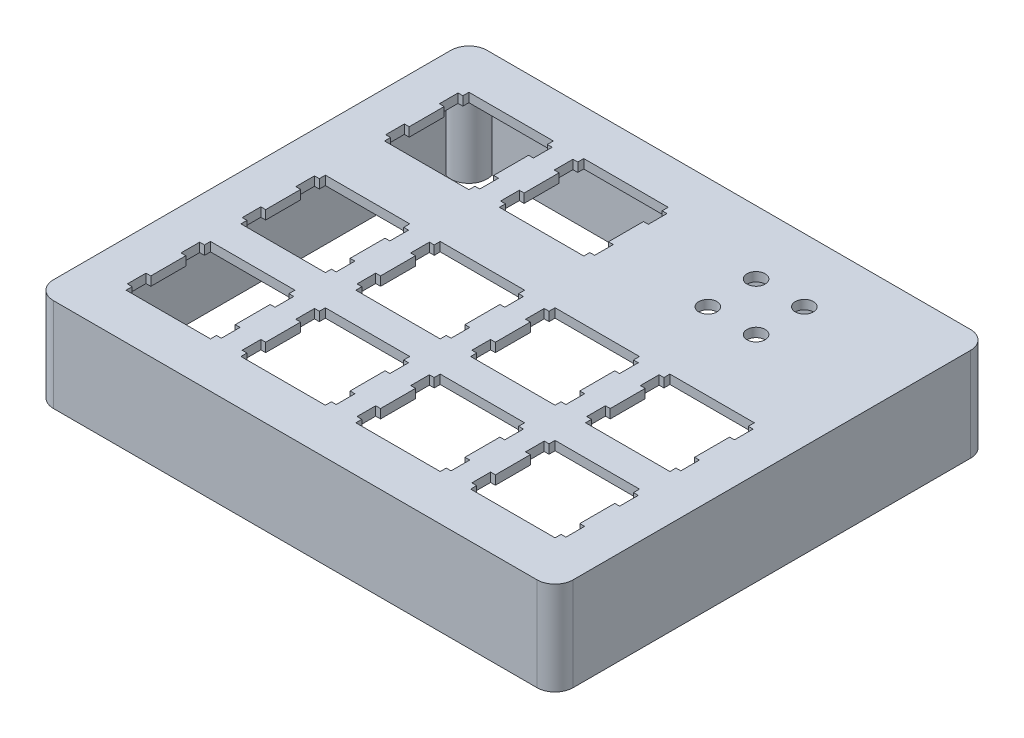
from build123d import *

# Parameters (mm, degrees)
MODEL_W                       = 86.200998775
MODEL_H                       = 71.913003996
MODEL_R                       = 1.5
BOSS_EXTRUDE1_DEPTH           = 1.5
SKETCH1_W                     = 86.200998775
SKETCH1_H                     = 71.913003996
SKETCH1_W_2                   = 82.200998775
SKETCH1_H_2                   = 67.913003996
EXTRUDE_THIN1_DEPTH           = 14
FILLET1_R                     = 3
SKETCH2_R                     = 3
BOSS_EXTRUDE2_DEPTH           = 14
TAP_DRILL_FOR_2_56_TAP1_D     = 1.778
TAP_DRILL_FOR_2_56_TAP1_DEPTH = 12.7
TAP_DRILL_FOR_2_56_TAP1_TIP   = 0.53416509
SKETCH6_W                     = 8
SKETCH6_H                     = 13
CUT_EXTRUDE1_DEPTH            = 2


with BuildPart() as part:
    # Model → Boss-Extrude1 (new body)
    with BuildSketch(Plane(origin=(0, 0, -8.60826899), x_dir=(1, 0, 0), z_dir=(0, 1, 0))):
        with Locations((43.100499388, 27.348233008)):
            Rectangle(MODEL_W, MODEL_H)
        with Locations((58.150003239, 52.780234713)):
            Circle(MODEL_R, mode=Mode.SUBTRACT)
        with Locations((66.150003239, 52.780234713)):
            Circle(MODEL_R, mode=Mode.SUBTRACT)
        with Locations((66.150003239, 44.780234713)):
            Circle(MODEL_R, mode=Mode.SUBTRACT)
        with Locations((58.150003239, 44.780234713)):
            Circle(MODEL_R, mode=Mode.SUBTRACT)
        Polygon((64.675004835, 12.91773258), (64.675004835, 11.917732552), (63.875001761, 11.917732552), (63.875001761, 8.817733992), (64.675004835, 8.817733992), (64.675004835, 3.017730781), (63.875001761, 3.017730781), (63.875001761, -0.082267779), (64.675004835, -0.082267779), (64.675004835, -1.082267806), (78.67500522, -1.082267806), (78.67500522, -0.082267779), (79.475000665, -0.082267779), (79.475000665, 3.017730781), (78.67500522, 3.017730781), (78.67500522, 8.817733992), (79.475000665, 8.817733992), (79.475000665, 11.917732552), (78.67500522, 11.917732552), (78.67500522, 12.91773258), align=None, mode=Mode.SUBTRACT)
        Polygon((45.625001258, 12.91773258), (45.625001258, 11.917732552), (44.825001999, 11.917732552), (44.825001999, 8.817733992), (45.625001258, 8.817733992), (45.625001258, 3.017730781), (44.825001999, 3.017730781), (44.825001999, -0.082267779), (45.625001258, -0.082267779), (45.625001258, -1.082267806), (59.625001644, -1.082267806), (59.625001644, -0.082267779), (60.425004717, -0.082267779), (60.425004717, 3.017730781), (59.625001644, 3.017730781), (59.625001644, 8.817733992), (60.425004717, 8.817733992), (60.425004717, 11.917732552), (59.625001644, 11.917732552), (59.625001644, 12.91773258), align=None, mode=Mode.SUBTRACT)
        Polygon((26.575001495, 12.91773258), (26.575001495, 11.917732552), (25.775000329, 11.917732552), (25.775000329, 8.817733992), (26.575001495, 8.817733992), (26.575001495, 3.017730781), (25.775000329, 3.017730781), (25.775000329, -0.082267779), (26.575001495, -0.082267779), (26.575001495, -1.082267806), (40.575001881, -1.082267806), (40.575001881, -0.082267779), (41.375001141, -0.082267779), (41.375001141, 3.017730781), (40.575001881, 3.017730781), (40.575001881, 8.817733992), (41.375001141, 8.817733992), (41.375001141, 11.917732552), (40.575001881, 11.917732552), (40.575001881, 12.91773258), align=None, mode=Mode.SUBTRACT)
        Polygon((7.524000375, 12.91773258), (7.524000375, 11.917732552), (6.724000162, 11.917732552), (6.724000162, 8.817733992), (7.524000375, 8.817733992), (7.524000375, 3.017730781), (6.724000162, 3.017730781), (6.724000162, -0.082267779), (7.524000375, -0.082267779), (7.524000375, -1.082267806), (21.525000212, -1.082267806), (21.525000212, -0.082267779), (22.325001378, -0.082267779), (22.325001378, 3.017730781), (21.525000212, 3.017730781), (21.525000212, 8.817733992), (22.325001378, 8.817733992), (22.325001378, 11.917732552), (21.525000212, 11.917732552), (21.525000212, 12.91773258), align=None, mode=Mode.SUBTRACT)
        Polygon((64.675004835, 31.967732342), (64.675004835, 30.967732314), (63.875001761, 30.967732314), (63.875001761, 27.867733755), (64.675004835, 27.867733755), (64.675004835, 22.067734358), (63.875001761, 22.067734358), (63.875001761, 18.967731983), (64.675004835, 18.967731983), (64.675004835, 17.967731956), (78.67500522, 17.967731956), (78.67500522, 18.967731983), (79.475000665, 18.967731983), (79.475000665, 22.067734358), (78.67500522, 22.067734358), (78.67500522, 27.867733755), (79.475000665, 27.867733755), (79.475000665, 30.967732314), (78.67500522, 30.967732314), (78.67500522, 31.967732342), align=None, mode=Mode.SUBTRACT)
        Polygon((45.625001258, 31.967732342), (45.625001258, 30.967732314), (44.825001999, 30.967732314), (44.825001999, 27.867733755), (45.625001258, 27.867733755), (45.625001258, 22.067734358), (44.825001999, 22.067734358), (44.825001999, 18.967731983), (45.625001258, 18.967731983), (45.625001258, 17.967731956), (59.625001644, 17.967731956), (59.625001644, 18.967731983), (60.425004717, 18.967731983), (60.425004717, 22.067734358), (59.625001644, 22.067734358), (59.625001644, 27.867733755), (60.425004717, 27.867733755), (60.425004717, 30.967732314), (59.625001644, 30.967732314), (59.625001644, 31.967732342), align=None, mode=Mode.SUBTRACT)
        Polygon((26.575001495, 31.967732342), (26.575001495, 30.967732314), (25.775000329, 30.967732314), (25.775000329, 27.867733755), (26.575001495, 27.867733755), (26.575001495, 22.067734358), (25.775000329, 22.067734358), (25.775000329, 18.967731983), (26.575001495, 18.967731983), (26.575001495, 17.967731956), (40.575001881, 17.967731956), (40.575001881, 18.967731983), (41.375001141, 18.967731983), (41.375001141, 22.067734358), (40.575001881, 22.067734358), (40.575001881, 27.867733755), (41.375001141, 27.867733755), (41.375001141, 30.967732314), (40.575001881, 30.967732314), (40.575001881, 31.967732342), align=None, mode=Mode.SUBTRACT)
        Polygon((7.524000375, 31.967732342), (7.524000375, 30.967732314), (6.724000162, 30.967732314), (6.724000162, 27.867733755), (7.524000375, 27.867733755), (7.524000375, 22.067734358), (6.724000162, 22.067734358), (6.724000162, 18.967731983), (7.524000375, 18.967731983), (7.524000375, 17.967731956), (21.525000212, 17.967731956), (21.525000212, 18.967731983), (22.325001378, 18.967731983), (22.325001378, 22.067734358), (21.525000212, 22.067734358), (21.525000212, 27.867733755), (22.325001378, 27.867733755), (22.325001378, 30.967732314), (21.525000212, 30.967732314), (21.525000212, 31.967732342), align=None, mode=Mode.SUBTRACT)
        Polygon((26.575001495, 55.780734631), (26.575001495, 54.780734603), (25.775000329, 54.780734603), (25.775000329, 51.679734686), (26.575001495, 51.679734686), (26.575001495, 45.880734739), (25.775000329, 45.880734739), (25.775000329, 42.779734822), (26.575001495, 42.779734822), (26.575001495, 41.779734794), (40.575001881, 41.779734794), (40.575001881, 42.779734822), (41.375001141, 42.779734822), (41.375001141, 45.880734739), (40.575001881, 45.880734739), (40.575001881, 51.679734686), (41.375001141, 51.679734686), (41.375001141, 54.780734603), (40.575001881, 54.780734603), (40.575001881, 55.780734631), align=None, mode=Mode.SUBTRACT)
        Polygon((7.524000375, 55.780734631), (7.524000375, 54.780734603), (6.724000162, 54.780734603), (6.724000162, 51.679734686), (7.524000375, 51.679734686), (7.524000375, 45.880734739), (6.724000162, 45.880734739), (6.724000162, 42.779734822), (7.524000375, 42.779734822), (7.524000375, 41.779734794), (21.525000212, 41.779734794), (21.525000212, 42.779734822), (22.325001378, 42.779734822), (22.325001378, 45.880734739), (21.525000212, 45.880734739), (21.525000212, 51.679734686), (22.325001378, 51.679734686), (22.325001378, 54.780734603), (21.525000212, 54.780734603), (21.525000212, 55.780734631), align=None, mode=Mode.SUBTRACT)
    extrude(amount=-BOSS_EXTRUDE1_DEPTH)

    # Sketch1 → Extrude-Thin1 (add)
    with BuildSketch(Plane(origin=(0, -1.5, 0), x_dir=(-1, 0, 0), z_dir=(0, -1, 0))):
        with Locations((-43.100499388, 35.956501998)):
            Rectangle(SKETCH1_W, SKETCH1_H)
        with Locations((-43.100499388, 35.956501998)):
            Rectangle(SKETCH1_W_2, SKETCH1_H_2, mode=Mode.SUBTRACT)
    extrude(amount=EXTRUDE_THIN1_DEPTH)

    # Fillet1
    fillet1_edges = [part.edges().sort_by_distance(p)[0] for p in [
        (86.200998775, -7.75, 0),
        (0, -7.75, 0),
        (0, -7.75, -71.913003996),
        (86.200998775, -7.75, -71.913003996),
    ]]
    fillet(fillet1_edges, radius=FILLET1_R)

    # Sketch2 → Boss-Extrude2 (add)
    with BuildSketch(Plane.XZ.offset(15.5)):
        with Locations((3, -3)):
            Circle(SKETCH2_R)
        with Locations((83.200998775, -3)):
            Circle(SKETCH2_R)
        with Locations((3, -68.913003996)):
            Circle(SKETCH2_R)
        with Locations((83.200998775, -68.913003996)):
            Circle(SKETCH2_R)
    extrude(amount=-BOSS_EXTRUDE2_DEPTH)

    # Tap Drill for #2-56 Tap1
    with Locations(Plane(origin=(0, -15.5, 0), x_dir=(-1, 0, 0), z_dir=(0, -1, 0))):
        with Locations((-3, 3), (-83.200998775, 3), (-83.200998775, 68.913003996), (-3, 68.913003996)):
            Hole(TAP_DRILL_FOR_2_56_TAP1_D / 2, depth=TAP_DRILL_FOR_2_56_TAP1_DEPTH)
            with Locations((0, 0, -(TAP_DRILL_FOR_2_56_TAP1_DEPTH + TAP_DRILL_FOR_2_56_TAP1_TIP / 2))):  # 118° drill point
                Cone(0, TAP_DRILL_FOR_2_56_TAP1_D / 2, TAP_DRILL_FOR_2_56_TAP1_TIP, mode=Mode.SUBTRACT)

    # Sketch6 → Cut-Extrude1 (cut)
    with BuildSketch(Plane(origin=(0, 0, -71.913003996), x_dir=(-1, 0, 0), z_dir=(0, 0, -1))):
        with Locations((-43.100499388, -15.5)):
            Rectangle(SKETCH6_W, SKETCH6_H)
    extrude(amount=-CUT_EXTRUDE1_DEPTH, mode=Mode.SUBTRACT)


solid = part.part
